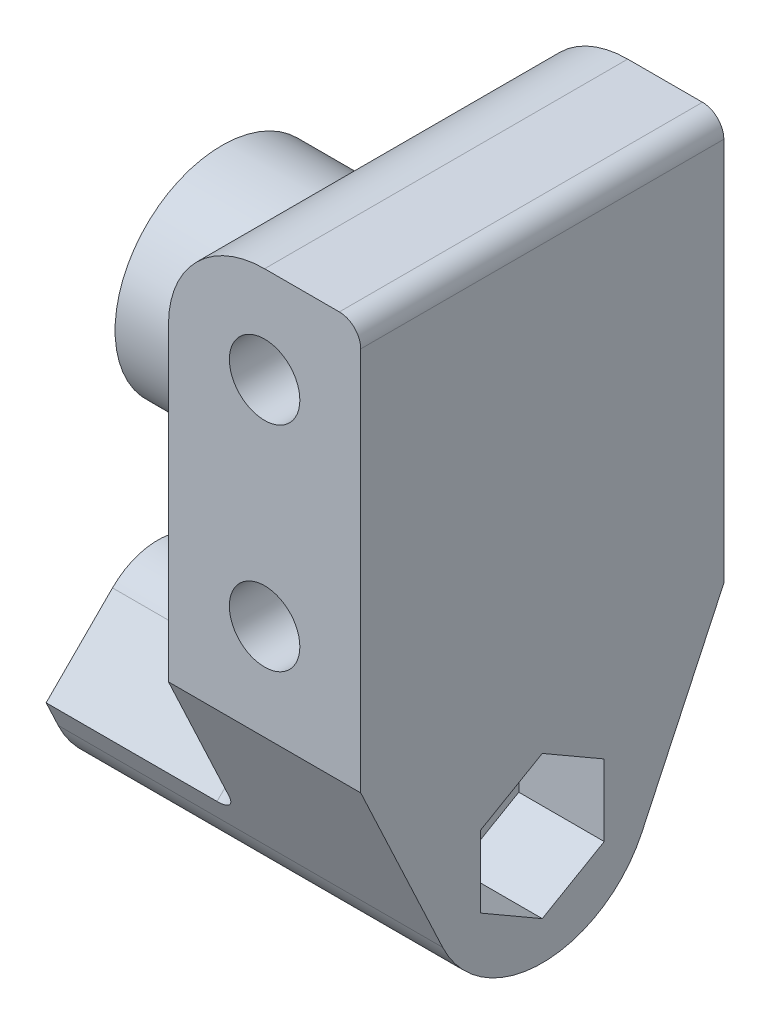
from build123d import *

# Parameters (mm, degrees)
SKETCH2_R           = 1.65
BOSS_EXTRUDE1_DEPTH = 17
BOSS_EXTRUDE2_START = -9
SKETCH3_R           = 1.65
BOSS_EXTRUDE2_DEPTH = 9
BOSS_EXTRUDE4_REACH = 21
SKETCH4_W           = 4.5
SKETCH4_H           = 17
CUT_EXTRUDE2_START  = -5
CUT_EXTRUDE2_DEPTH  = 13
SKETCH11_R          = 5
BOSS_EXTRUDE5_DEPTH = 6
FILLET1_R           = 1
FILLET2_R           = 1
SKETCH12_R          = 1.65
BOSS_EXTRUDE6_DEPTH = 9
FILLET3_R           = 1


with BuildPart() as part:
    # Sketch2 → Boss-Extrude1 (new body)
    with BuildSketch(Plane.XY):
        with BuildLine():
            Line((-4.5, 0), (-4.5, 10))
            ThreePointArc((-4.5, 10), (-3.181980515, 13.181980515), (0, 14.5))
            Line((0, 14.5), (4.5, 14.5))
            Line((4.5, 14.5), (4.5, -4.5))
            Line((4.5, -4.5), (0, -4.5))
            ThreePointArc((0, -4.5), (-3.181980515, -3.181980515), (-4.5, 0))
        make_face()
        with Locations((0, 10)):
            Circle(SKETCH2_R, mode=Mode.SUBTRACT)
        Circle(SKETCH2_R, mode=Mode.SUBTRACT)
    extrude(amount=BOSS_EXTRUDE1_DEPTH)

    # Sketch3 → Boss-Extrude2 (add)
    with BuildSketch(Plane(origin=(4.5, 0, 0), x_dir=(0, 0, -1), z_dir=(1, 0, 0)).offset(BOSS_EXTRUDE2_START)):
        with BuildLine():
            Line((-13.163162433, -12.685730113), (-17, -4.5))
            Line((-17, -4.5), (0, -4.5))
            Line((0, -4.5), (-3.836837567, -12.685730113))
            ThreePointArc((-3.836837567, -12.685730113), (-8.5, -15.65), (-13.163162433, -12.685730113))
        make_face()
        with Locations((-8.5, -10.5)):
            Circle(SKETCH3_R, mode=Mode.SUBTRACT)
    extrude(amount=BOSS_EXTRUDE2_DEPTH)

    # Sketch4 → Boss-Extrude4 (add, up to next)
    with BuildSketch(Plane(origin=(0, -4.5, 0), x_dir=(1, 0, 0), z_dir=(0, 1, 0)), mode=Mode.PRIVATE) as boss_extrude4_sk1:
        with Locations((-2.25, -8.5)):
            Rectangle(SKETCH4_W, SKETCH4_H)
    boss_extrude4_tool1 = extrude(boss_extrude4_sk1.sketch, amount=BOSS_EXTRUDE4_REACH, mode=Mode.PRIVATE) - part.part
    add(boss_extrude4_tool1.solids().sort_by_distance((-2.25, -4.5, 8.5))[0])

    # Sketch8 → Cut-Extrude2 (cut)
    with BuildSketch(Plane.ZY.offset(4.5).offset(CUT_EXTRUDE2_START)):
        Polygon((8.5, -7.151368439), (5.6, -8.825684219), (5.6, -12.174315781), (8.5, -13.848631561), (11.4, -12.174315781), (11.4, -8.825684219), align=None)
    extrude(amount=-CUT_EXTRUDE2_DEPTH, mode=Mode.SUBTRACT)

    # Sketch11 → Boss-Extrude5 (add)
    with BuildSketch(Plane(origin=(-4.5, 0, 0), x_dir=(0, 0, -1), z_dir=(1, 0, 0))):
        with Locations((-8.5, 5)):
            Circle(SKETCH11_R)
    extrude(amount=-BOSS_EXTRUDE5_DEPTH)

    # Fillet1
    fillet1_edges = [part.edges().sort_by_distance(p)[0] for p in [
        (-4.5, 8.535533906, 4.964466094),
    ]]
    fillet(fillet1_edges, radius=FILLET1_R)

    # Fillet2
    fillet2_edges = [part.edges().sort_by_distance(p)[0] for p in [
        (4.5, 14.5, 8.5),
    ]]
    fillet(fillet2_edges, radius=FILLET2_R)

    # Sketch12 → Boss-Extrude6 (add)
    with BuildSketch(Plane.ZY.offset(4.5)):
        with BuildLine():
            Line((13.163162433, -12.685730113), (13.726504471, -11.483863783))
            Line((13.726504471, -11.483863783), (10.621320344, -8.378679656))
            ThreePointArc((10.621320344, -8.378679656), (8.5, -7.5), (6.378679656, -8.378679656))
            Line((6.378679656, -8.378679656), (3.273495529, -11.483863783))
            Line((3.273495529, -11.483863783), (3.836837567, -12.685730113))
            ThreePointArc((3.836837567, -12.685730113), (8.5, -15.65), (13.163162433, -12.685730113))
        make_face()
        with Locations((8.5, -10.5)):
            Circle(SKETCH12_R, mode=Mode.SUBTRACT)
    extrude(amount=BOSS_EXTRUDE6_DEPTH)

    # Fillet3
    fillet3_edges = [part.edges().sort_by_distance(p)[0] for p in [
        (-4.5, -7.5, 8.5),
        (-4.5, -9.93127172, 4.826087593),
        (-4.5, -9.93127172, 12.173912407),
    ]]
    fillet(fillet3_edges, radius=FILLET3_R)


solid = part.part
